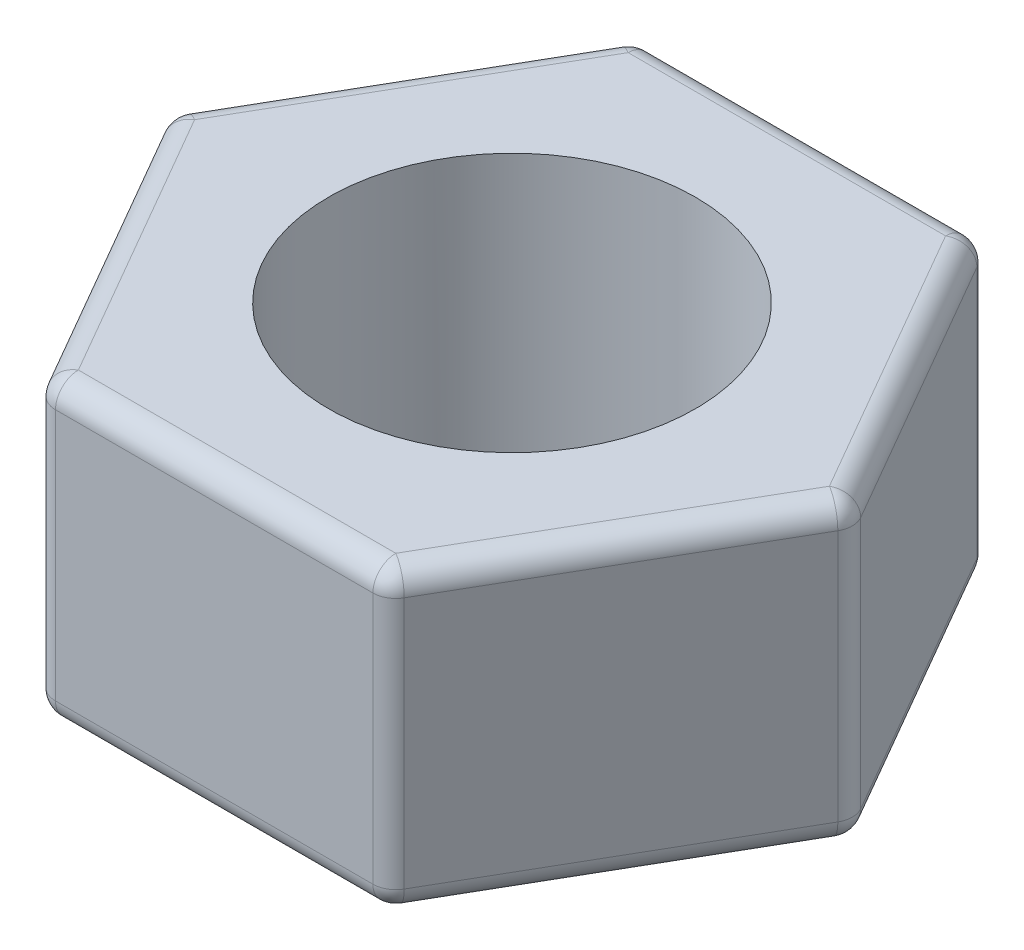
from build123d import *

# Parameters (mm, degrees)
EXTRUDE3_DEPTH = 6.5
FILLET3_R      = 0.5
SKETCH2_R      = 4
EXTRUDE4_DEPTH = 6.5
FILLET5_R      = 0.5


with BuildPart() as part:
    # Sketch1 → Extrude3 (new body)
    with BuildSketch(Plane(origin=(0, 0, 0), x_dir=(1, 0, 0), z_dir=(0, 1, 0))):
        Polygon((7.5, 0), (3.75, 6.495190528), (-3.75, 6.495190528), (-7.5, 0), (-3.75, -6.495190528), (3.75, -6.495190528), align=None)
    extrude(amount=EXTRUDE3_DEPTH)

    # Fillet3
    fillet3_edges = [part.edges().sort_by_distance(p)[0] for p in [
        (0, 6.5, -6.495190528),
        (3.75, 3.25, 6.495190528),
        (-3.75, 3.25, 6.495190528),
        (-7.5, 3.25, 0),
        (-3.75, 3.25, -6.495190528),
        (3.75, 3.25, -6.495190528),
        (7.5, 3.25, 0),
        (-5.625, 6.5, -3.247595264),
        (-5.625, 6.5, 3.247595264),
        (0, 6.5, 6.495190528),
        (5.625, 6.5, 3.247595264),
        (0, 0, 6.495190528),
        (-5.625, 0, 3.247595264),
        (-5.625, 0, -3.247595264),
        (5.625, 6.5, -3.247595264),
        (0, 0, -6.495190528),
        (5.625, 0, -3.247595264),
        (5.625, 0, 3.247595264),
    ]]
    fillet(fillet3_edges, radius=FILLET3_R)

    # Sketch2 → Extrude4 (cut)
    with BuildSketch(Plane.XZ):
        Circle(SKETCH2_R)
    extrude(amount=-EXTRUDE4_DEPTH, mode=Mode.SUBTRACT)

    # Fillet5
    fillet5_edges = [part.edges().sort_by_distance(p)[0] for p in [
        (-4, 0, 0),
    ]]
    fillet(fillet5_edges, radius=FILLET5_R)


solid = part.part
